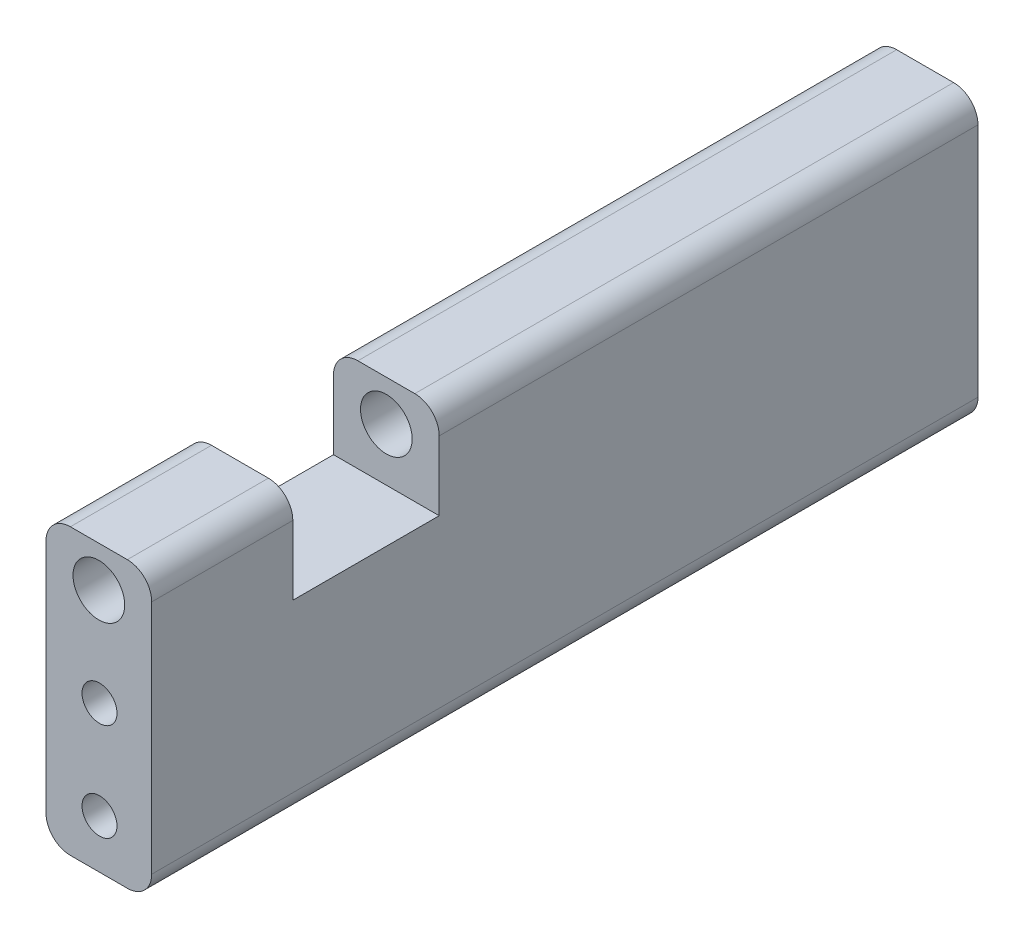
from build123d import *

# Parameters (mm, degrees)
SKETCH1_W                = 13
SKETCH1_H                = 35
SKETCH1_R                = 3.175
BOSS_EXTRUDE1_DEPTH      = 101.6
CUT_EXTRUDE1_DEPTH       = 9
M4_CLEARANCE_HOLE1_D     = 4.3
M4_CLEARANCE_HOLE1_DEPTH = 5
M4_CLEARANCE_HOLE1_TIP   = 1.291850331
M4_CLEARANCE_HOLE2_D     = 4.3
M4_CLEARANCE_HOLE2_DEPTH = 5
M4_CLEARANCE_HOLE2_TIP   = 1.291850331
FILLET1_R                = 3


with BuildPart() as part:
    # Sketch1 → Boss-Extrude1 (new body)
    with BuildSketch(Plane.XY):
        with Locations((6.5, 17.5)):
            Rectangle(SKETCH1_W, SKETCH1_H)
        with Locations((6.5, 30)):
            Circle(SKETCH1_R, mode=Mode.SUBTRACT)
    extrude(amount=BOSS_EXTRUDE1_DEPTH)

    # Sketch2 → Cut-Extrude1 (cut, symmetric)
    with BuildSketch(Plane.XY.offset(75.25)):
        Polygon((0, 30), (0, 35), (13, 35), (13, 30), (13, 23.5), (0, 23.5), align=None)
    extrude(amount=CUT_EXTRUDE1_DEPTH, both=True, mode=Mode.SUBTRACT)

    # M4 Clearance Hole1
    with Locations(Plane(origin=(0, 0, 0), x_dir=(-1, 0, 0), z_dir=(0, 0, -1))):
        with Locations((-6.579246302, 18), (-6.579246302, 6)):
            Hole(M4_CLEARANCE_HOLE1_D / 2, depth=M4_CLEARANCE_HOLE1_DEPTH)
            with Locations((0, 0, -(M4_CLEARANCE_HOLE1_DEPTH + M4_CLEARANCE_HOLE1_TIP / 2))):  # 118° drill point
                Cone(0, M4_CLEARANCE_HOLE1_D / 2, M4_CLEARANCE_HOLE1_TIP, mode=Mode.SUBTRACT)

    # M4 Clearance Hole2
    with Locations(Plane.XY.offset(101.6)):
        with Locations((6.579246302, 18), (6.579246302, 6)):
            Hole(M4_CLEARANCE_HOLE2_D / 2, depth=M4_CLEARANCE_HOLE2_DEPTH)
            with Locations((0, 0, -(M4_CLEARANCE_HOLE2_DEPTH + M4_CLEARANCE_HOLE2_TIP / 2))):  # 118° drill point
                Cone(0, M4_CLEARANCE_HOLE2_D / 2, M4_CLEARANCE_HOLE2_TIP, mode=Mode.SUBTRACT)

    # Fillet1
    fillet1_edges = [part.edges().sort_by_distance(p)[0] for p in [
        (0, 35, 33.125),
        (13, 35, 33.125),
        (0, 35, 92.925),
        (13, 35, 92.925),
        (13, 0, 50.8),
        (0, 0, 50.8),
    ]]
    fillet(fillet1_edges, radius=FILLET1_R)


solid = part.part
